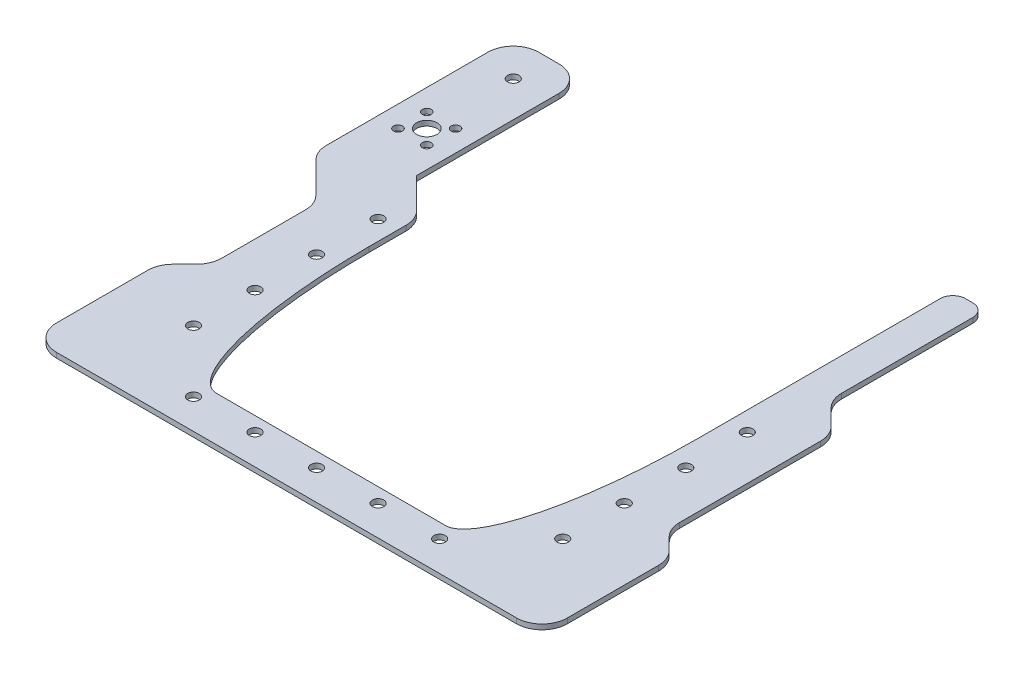
from build123d import *

# Parameters (mm, degrees)
BOSS_EXTRUDE1_DEPTH = 2
SKETCH2_R           = 1.75
SKETCH2_R_2         = 4
SKETCH2_R_3         = 2.25
CUT_EXTRUDE2_DEPTH  = 3
FILLET1_R           = 10
BOSS_EXTRUDE3_DEPTH = 2
FILLET3_R           = 5
SKETCH4_R           = 2.25
CUT_EXTRUDE3_DEPTH  = 3.0000001


with BuildPart() as part:
    # Sketch1 → Boss-Extrude1 (new body)
    with BuildSketch(Plane(origin=(0, 0, 0), x_dir=(1, 0, 0), z_dir=(0, 1, 0))):
        Polygon((0, 0), (0, -98.655), (130, -98.655), (130, 80.835), (142.835, 80.835), (142.835, 20.135), (155, 7.97), (155, -55.71), (165.445, -66.155), (165.445, -116.155), (-35.445, -116.155), (-35.445, -66.155), (-25, -55.71), (-25, -14.597979746), (-42.835, 3.237020254), (-42.835, 80.835), (-14.835, 80.835), (-14.835, 14.835), align=None)
    extrude(amount=BOSS_EXTRUDE1_DEPTH)

    # Sketch2 → Cut-Extrude2 (cut, through all)
    with BuildSketch(Plane(origin=(0, 2, 0), x_dir=(1, 0, 0), z_dir=(0, 1, 0))):
        with Locations((-23.178145751, 38.49185425)):
            Circle(SKETCH2_R)
        with Locations((-23.178145751, 27.178145751)):
            Circle(SKETCH2_R)
        with Locations((-34.491854249, 27.178145751)):
            Circle(SKETCH2_R)
        with Locations((-34.491854249, 38.49185425)):
            Circle(SKETCH2_R)
        with Locations((-28.835, 32.835)):
            Circle(SKETCH2_R_2)
        with Locations((137.585, -80.14)):
            Circle(SKETCH2_R_3)
        with Locations((-7.585, -80.14)):
            Circle(SKETCH2_R_3)
        with Locations((137.585, -55.945)):
            Circle(SKETCH2_R_3)
        with Locations((-7.585, -55.945)):
            Circle(SKETCH2_R_3)
        with Locations((137.585, -31.75)):
            Circle(SKETCH2_R_3)
        with Locations((-7.585, -31.75)):
            Circle(SKETCH2_R_3)
        with Locations((137.585, -7.555)):
            Circle(SKETCH2_R_3)
        with Locations((-7.585, -7.555)):
            Circle(SKETCH2_R_3)
        with Locations((16.61, -104.335)):
            Circle(SKETCH2_R_3)
        with Locations((40.805, -104.335)):
            Circle(SKETCH2_R_3)
        with Locations((65, -104.335)):
            Circle(SKETCH2_R_3)
        with Locations((89.195, -104.335)):
            Circle(SKETCH2_R_3)
        with Locations((113.39, -104.335)):
            Circle(SKETCH2_R_3)
    extrude(amount=-CUT_EXTRUDE2_DEPTH, mode=Mode.SUBTRACT)

    # Fillet1
    fillet1_edges = [part.edges().sort_by_distance(p)[0] for p in [
        (0, 1, 0),
        (142.835, 1, -20.135),
        (155, 1, -7.97),
        (155, 1, 55.71),
        (165.445, 1, 66.155),
        (165.445, 1, 116.155),
        (-35.445, 1, 116.155),
        (-35.445, 1, 66.155),
        (-25, 1, 55.71),
        (-25, 1, 14.597979746),
        (-42.835, 1, -3.237020254),
        (-42.835, 1, -80.835),
        (-14.835, 1, -80.835),
    ]]
    fillet(fillet1_edges, radius=FILLET1_R)

    # Sketch3 → Boss-Extrude3 (add, through all)
    with BuildSketch(Plane(origin=(0, 2, 0), x_dir=(1, 0, 0), z_dir=(0, 1, 0))):
        with BuildLine():
            Line((0, -18.655), (0, -98.655))
            Line((0, -98.655), (20, -98.655))
            add(Edge.make_bspline(
                [(0, -18.655), (0, -98.655), (20, -98.655)],
                knots=[4.71238898, 4.71238898, 4.71238898, 6.283185307, 6.283185307, 6.283185307], degree=2, weights=[1, 0.707106781, 1]))
        make_face()
        with BuildLine():
            Line((130, -98.655), (110, -98.655))
            add(Edge.make_bspline(
                [(110, -98.655), (130, -98.655), (130, -18.655)],
                knots=[0, 0, 0, 1.570796327, 1.570796327, 1.570796327], degree=2, weights=[1, 0.707106781, 1]))
            Line((130, -18.655), (130, -98.655))
        make_face()
    extrude(amount=-BOSS_EXTRUDE3_DEPTH)

    # Fillet3
    fillet3_edges = [part.edges().sort_by_distance(p)[0] for p in [
        (130, 1, -80.835),
        (142.835, 1, -80.835),
    ]]
    fillet(fillet3_edges, radius=FILLET3_R)

    # Sketch4 → Cut-Extrude3 (cut, through all)
    with BuildSketch(Plane(origin=(0, 2, 0), x_dir=(1, 0, 0), z_dir=(0, 1, 0))):
        with Locations((-28.835, 66.835)):
            Circle(SKETCH4_R)
    extrude(amount=-CUT_EXTRUDE3_DEPTH, mode=Mode.SUBTRACT)


solid = part.part
